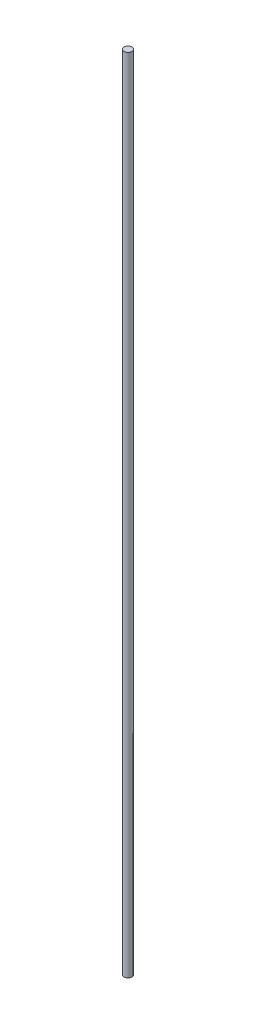
from build123d import *

# Parameters (mm, degrees)
SKETCH1_R           = 0.95
BOSS_EXTRUDE1_DEPTH = 194


with BuildPart() as part:
    # Sketch1 → Boss-Extrude1 (new body)
    with BuildSketch(Plane(origin=(0, 0, 0), x_dir=(1, 0, 0), z_dir=(0, 1, 0))):
        Circle(SKETCH1_R)
    extrude(amount=BOSS_EXTRUDE1_DEPTH)


solid = part.part
